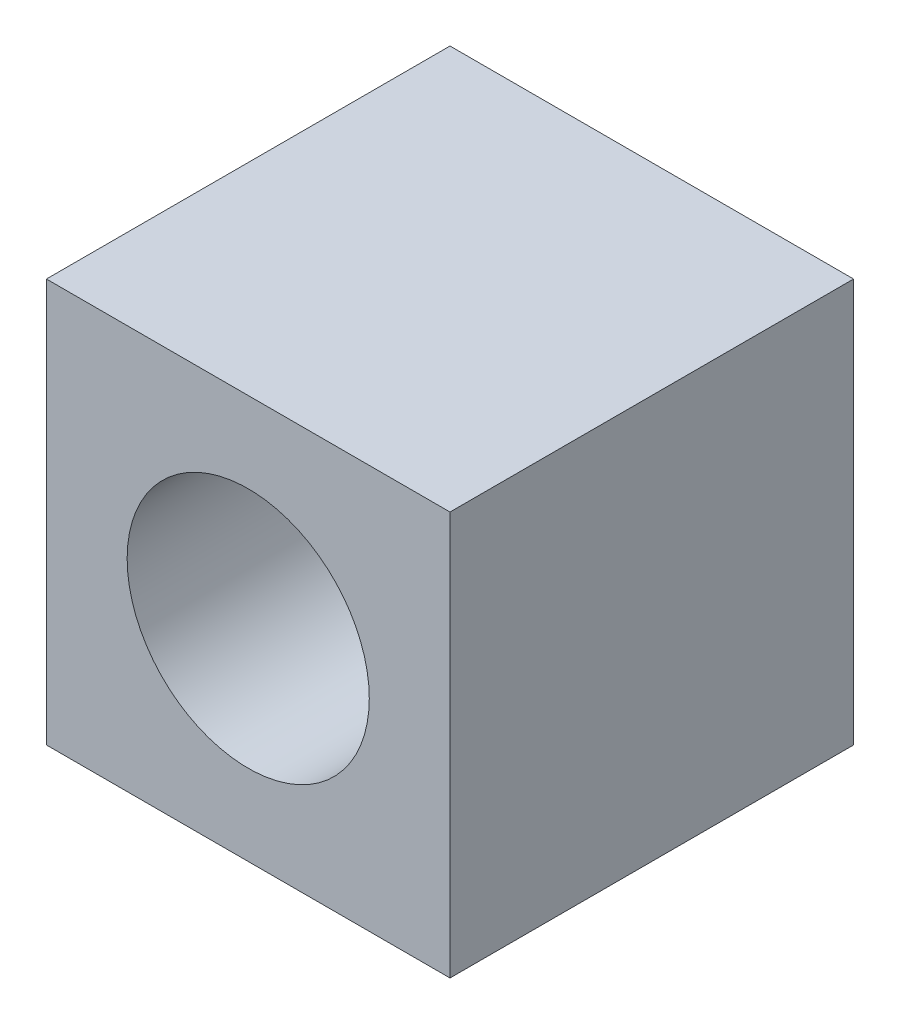
from build123d import *

# Parameters (mm, degrees)
SKETCH1_W           = 10
SKETCH1_H           = 10
BOSS_EXTRUDE1_DEPTH = 10
SKETCH2_R           = 3
CUT_EXTRUDE1_DEPTH  = 10


with BuildPart() as part:
    # Sketch1 → Boss-Extrude1 (new body)
    with BuildSketch(Plane(origin=(0, 0, 0), x_dir=(1, 0, 0), z_dir=(0, 1, 0))):
        with Locations((5, 5)):
            Rectangle(SKETCH1_W, SKETCH1_H)
    extrude(amount=BOSS_EXTRUDE1_DEPTH)

    # Sketch2 → Cut-Extrude1 (cut)
    with BuildSketch(Plane.XY):
        with Locations((5, 5)):
            Circle(SKETCH2_R)
    extrude(amount=-CUT_EXTRUDE1_DEPTH, mode=Mode.SUBTRACT)


solid = part.part
